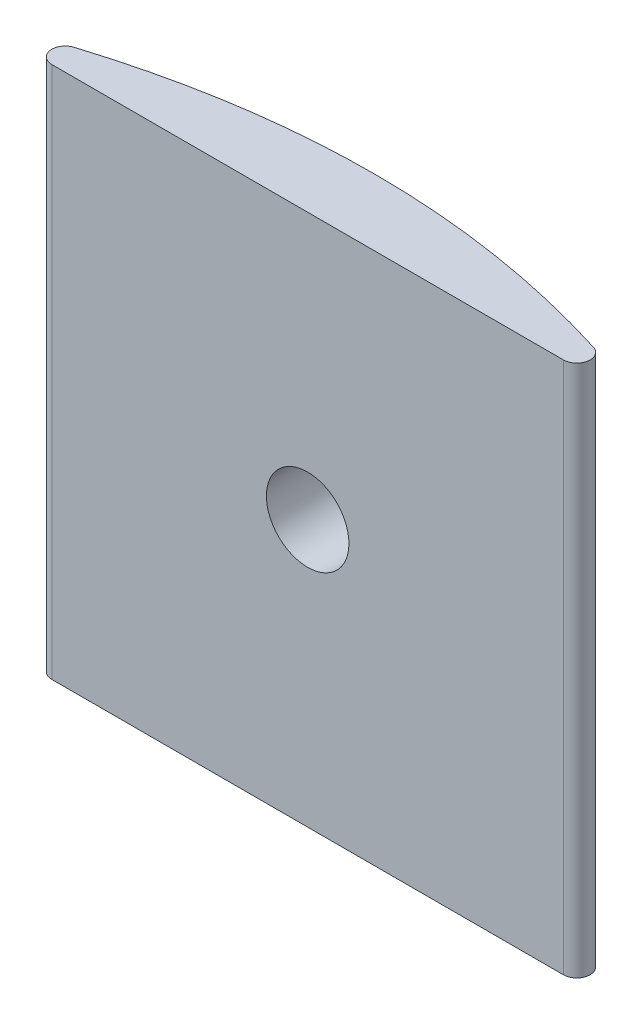
from build123d import *

# Parameters (mm, degrees)
BOSS_EXTRUDE1_DEPTH = 20
SKETCH2_R           = 1.55
CUT_EXTRUDE1_DEPTH  = 20
FILLET1_R           = 0.5


with BuildPart() as part:
    # Sketch1 → Boss-Extrude1 (new body)
    with BuildSketch(Plane(origin=(0, 0, 0), x_dir=(1, 0, 0), z_dir=(0, 1, 0))):
        with BuildLine():
            add(Edge.make_bspline(
                [(0, 0), (6.25, 2.5), (12.5, 2.5)],
                knots=[0, 0, 0, 0.5, 0.5, 0.5], degree=2))
            Line((0, 0), (12.5, 0))
            Line((12.5, 0), (12.5, 2.5))
        make_face()
        with BuildLine():
            Line((12.5, 2.5), (12.5, 0))
            Line((12.5, 0), (25, 0))
            add(Edge.make_bspline(
                [(12.5, 2.5), (18.75, 2.5), (25, 0)],
                knots=[0.5, 0.5, 0.5, 1, 1, 1], degree=2))
        make_face()
    extrude(amount=BOSS_EXTRUDE1_DEPTH)

    # Sketch2 → Cut-Extrude1 (cut)
    with BuildSketch(Plane.XY):
        with Locations((12.5, 10)):
            Circle(SKETCH2_R)
    extrude(amount=-CUT_EXTRUDE1_DEPTH, mode=Mode.SUBTRACT)

    # Fillet1
    fillet1_edges = [part.edges().sort_by_distance(p)[0] for p in [
        (0, 10, 0),
        (25, 10, 0),
    ]]
    fillet(fillet1_edges, radius=FILLET1_R)


solid = part.part
